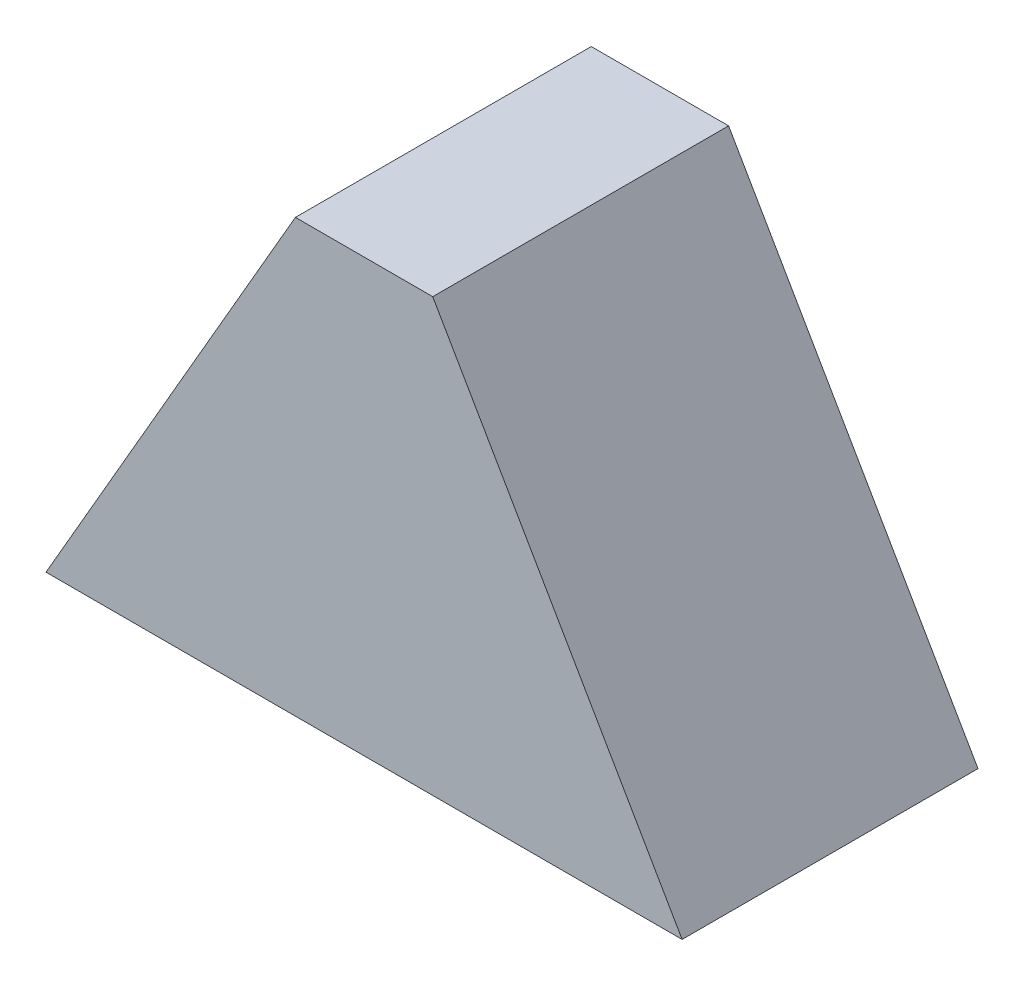
from build123d import *

# Parameters (mm, degrees)
EXTRUDE_1_DEPTH = 200


with BuildPart() as part:
    # 草图1 → 凸台-拉伸1 (new body)
    with BuildSketch(Plane.XY):
        Polygon((0, 0), (168.586278603, 292), (261.413721397, 292), (430, 0), align=None)
    extrude(amount=EXTRUDE_1_DEPTH)


solid = part.part
